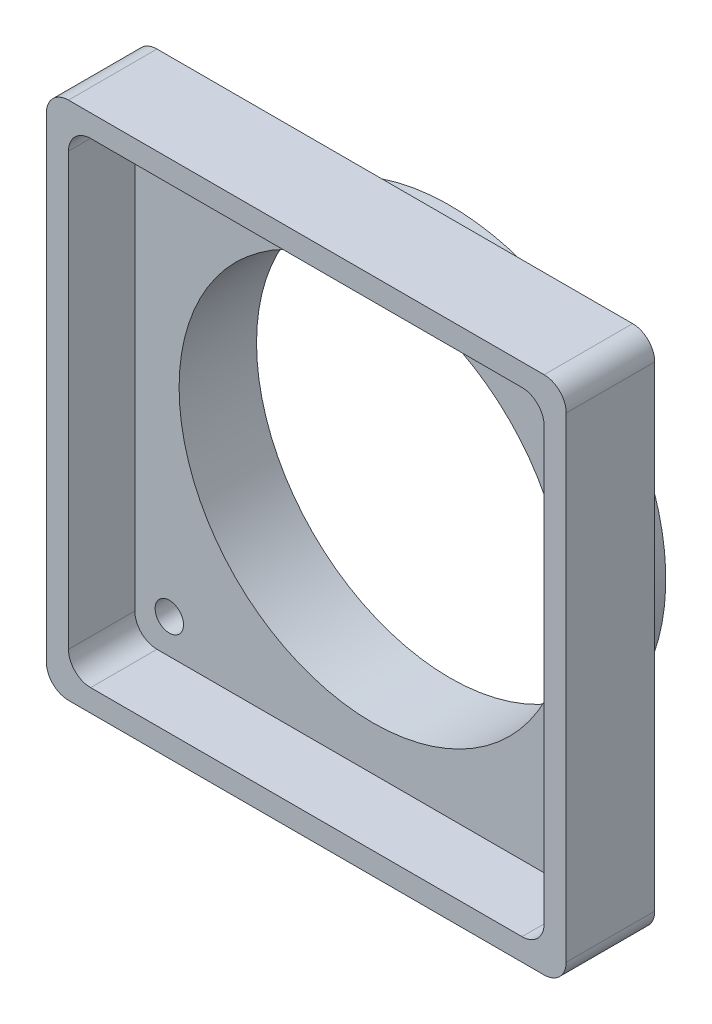
from build123d import *

# Parameters (mm, degrees)
BOSS_EXTRUDE1_DEPTH = 16.51
SKETCH2_R           = 22.225
CUT_EXTRUDE1_DEPTH  = 17.51
SKETCH4_OUTSIDE_W   = 78.892
SKETCH4_OUTSIDE_H   = 78.892
SKETCH4_OUTSIDE_R   = 24.765
CUT_EXTRUDE2_DEPTH  = 6.35
CUT_EXTRUDE3_DEPTH  = 7.62
CIRPATTERN1_COUNT   = 4


with BuildPart() as part:
    # Sketch1 → Boss-Extrude1 (new body)
    with BuildSketch(Plane.XY):
        with BuildLine():
            Line((-27.305, 29.845), (27.305, 29.845))
            ThreePointArc((27.305, 29.845), (29.101051224, 29.101051224), (29.845, 27.305))
            Line((29.845, 27.305), (29.845, -27.305))
            ThreePointArc((29.845, -27.305), (29.101051224, -29.101051224), (27.305, -29.845))
            Line((27.305, -29.845), (-27.305, -29.845))
            ThreePointArc((-27.305, -29.845), (-29.101051224, -29.101051224), (-29.845, -27.305))
            Line((-29.845, -27.305), (-29.845, 27.305))
            ThreePointArc((-29.845, 27.305), (-29.101051224, 29.101051224), (-27.305, 29.845))
        make_face()
    extrude(amount=BOSS_EXTRUDE1_DEPTH)

    # Sketch2 → Cut-Extrude1 (cut, through all)
    with BuildSketch(Plane.XY.offset(16.51)):
        Circle(SKETCH2_R)
    extrude(amount=-CUT_EXTRUDE1_DEPTH, mode=Mode.SUBTRACT)

    # Sketch4 outside → Cut-Extrude2 (cut)
    with BuildSketch(Plane(origin=(0, 0, 0), x_dir=(-1, 0, 0), z_dir=(0, 0, -1))):
        Rectangle(SKETCH4_OUTSIDE_W, SKETCH4_OUTSIDE_H)
        Circle(SKETCH4_OUTSIDE_R, mode=Mode.SUBTRACT)
    extrude(amount=-CUT_EXTRUDE2_DEPTH, mode=Mode.SUBTRACT)

    # Sketch3 → Cut-Extrude3 (cut)
    with BuildSketch(Plane.XY.offset(16.51)):
        with BuildLine():
            Line((24.765, -27.305), (-24.765, -27.305))
            ThreePointArc((-24.765, -27.305), (-26.561051224, -26.561051224), (-27.305, -24.765))
            Line((-27.305, -24.765), (-27.305, 24.765))
            ThreePointArc((-27.305, 24.765), (-26.561051224, 26.561051224), (-24.765, 27.305))
            Line((-24.765, 27.305), (24.765, 27.305))
            ThreePointArc((24.765, 27.305), (26.561051224, 26.561051224), (27.305, 24.765))
            Line((27.305, 24.765), (27.305, -24.765))
            ThreePointArc((27.305, -24.765), (26.561051224, -26.561051224), (24.765, -27.305))
        make_face()
    extrude(amount=-CUT_EXTRUDE3_DEPTH, mode=Mode.SUBTRACT)

    # Sketch6 → #4 Clearance Hole1 (revolve, cut)
    with BuildSketch(Plane(origin=(-23.348665915, 23.348665915, 8.89), x_dir=(0, -1, 0), z_dir=(1, 0, 0))):
        Polygon((0, 0), (0, 8.575174487), (1.63195, 7.5946), (1.63195, 0), align=None)
    f_4_clearance_hole1 = revolve(axis=Axis((-23.348665915, 23.348665915, 15.24), (0, 0, -1)), mode=Mode.SUBTRACT)

    # CirPattern1: #4 Clearance Hole1 ×4 about axis
    cirpattern1_axis = Axis((0, 0, 0), (0, 0, 1))
    for i in range(1, CIRPATTERN1_COUNT):
        add(f_4_clearance_hole1.rotate(cirpattern1_axis, i * 360 / CIRPATTERN1_COUNT), mode=Mode.SUBTRACT)


solid = part.part
